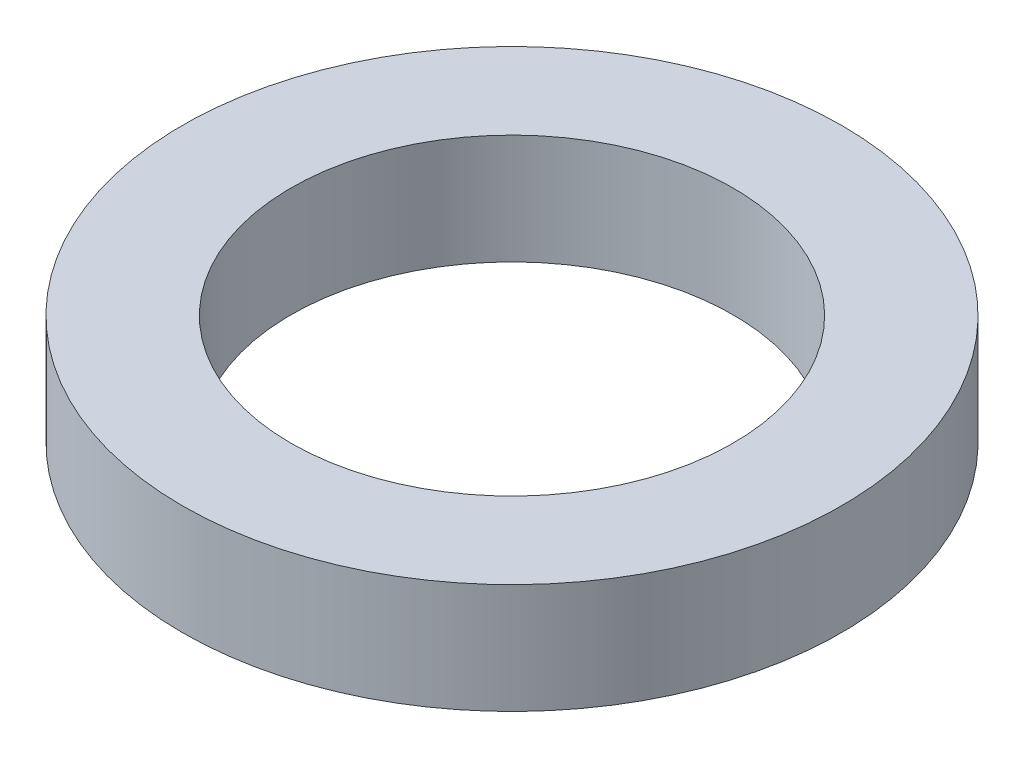
from build123d import *

# Parameters (mm, degrees)
SKETCH1_R           = 6
SKETCH1_R_2         = 4.025
BOSS_EXTRUDE1_DEPTH = 2


with BuildPart() as part:
    # Sketch1 → Boss-Extrude1 (new body)
    with BuildSketch(Plane(origin=(0, 0, 0), x_dir=(1, 0, 0), z_dir=(0, 1, 0))):
        Circle(SKETCH1_R)
        Circle(SKETCH1_R_2, mode=Mode.SUBTRACT)
    extrude(amount=BOSS_EXTRUDE1_DEPTH)


solid = part.part
